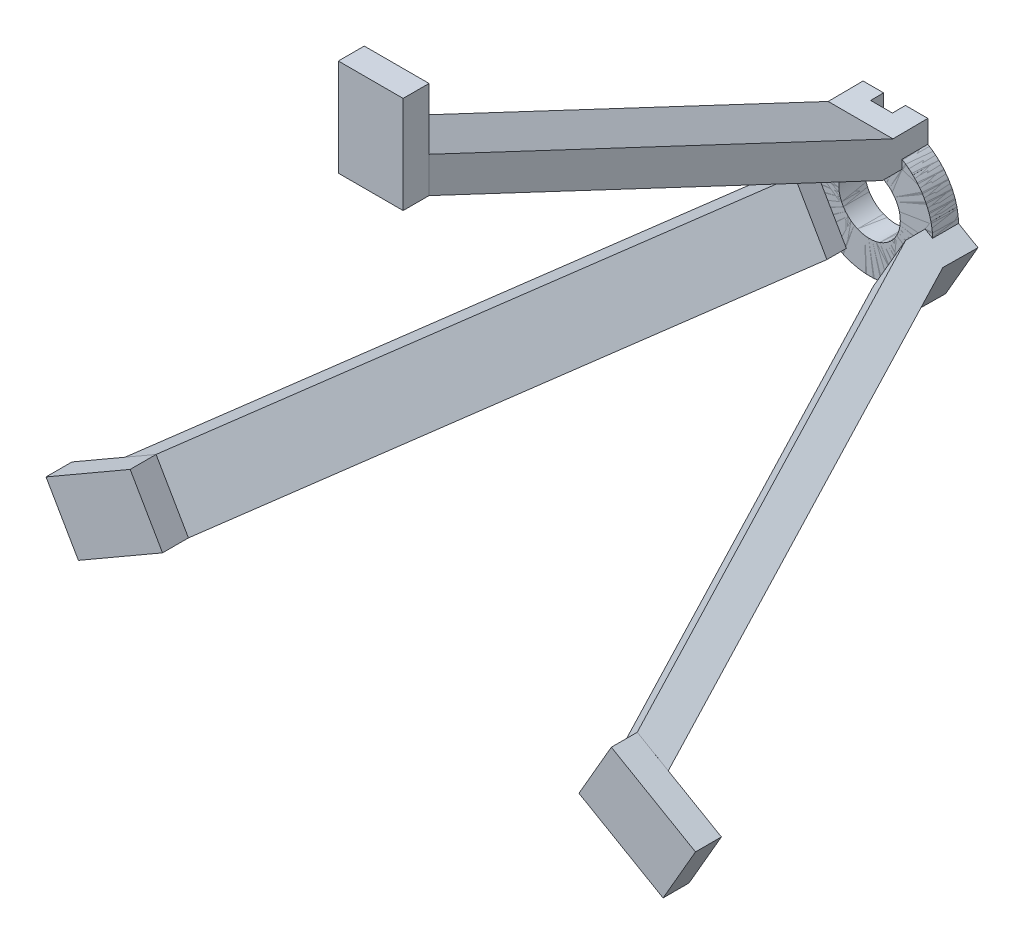
from build123d import *

# Parameters (mm, degrees)
SKETCH1_R                = 4.75
BOSS_EXTRUDE1_DEPTH      = 4
SKETCH2_W                = 10
SKETCH2_H                = 3.269716928
BOSS_EXTRUDE3_DEPTH      = 3
BOSS_EXTRUDE3_DEPTH_BACK = 2
SKETCH6_W                = 10
SKETCH6_H                = 15
BOSS_EXTRUDE4_DEPTH      = 4
BOSS_EXTRUDE5_DEPTH      = 10
CIRPATTERN1_COUNT        = 3
SKETCH8_W                = 3.367555941
SKETCH8_H                = 5.226269066
CUT_EXTRUDE1_DEPTH       = 2


with BuildPart() as part:
    # Sketch1 → Boss-Extrude1 (new body)
    with BuildSketch(Plane.XY):
        with BuildLine():
            Line((6.690811411, 7.091935043), (-6.690811411, 7.091935043))
            ThreePointArc((-6.690811411, 7.091935043), (-3.861805843, -8.95259491), (9.75, 0))
            ThreePointArc((9.75, 0), (8.95259491, 3.861805843), (6.690811411, 7.091935043))
        make_face()
        Circle(SKETCH1_R, mode=Mode.SUBTRACT)
    extrude(amount=BOSS_EXTRUDE1_DEPTH)

    # Sketch2 → Boss-Extrude3 (add, two sides)
    with BuildSketch(Plane.XY.offset(4)) as boss_extrude3_sk:
        with Locations((0, 8.652125422)):
            Rectangle(SKETCH2_W, SKETCH2_H)
    extrude(amount=BOSS_EXTRUDE3_DEPTH)
    extrude(boss_extrude3_sk.sketch, amount=-BOSS_EXTRUDE3_DEPTH_BACK)

    # Sketch7 → Boss-Extrude5 (add)
    with BuildSketch(Plane.ZY.offset(5)):
        Polygon((77, 40), (7, 7.017266958), (0, 7.017266958), (0, 11.828521069), (5.385727043, 11.783884206), (76.99663738, 45.525649042), align=None)
    extrude(amount=-BOSS_EXTRUDE5_DEPTH)


with BuildPart() as body_2:
    # Sketch6 → Boss-Extrude4 (new body)
    with BuildSketch(Plane.XY.offset(81)):
        with Locations((0, 47.5)):
            Rectangle(SKETCH6_W, SKETCH6_H)
    extrude(amount=-BOSS_EXTRUDE4_DEPTH)


with BuildPart() as cirpattern1_1:
    # CirPattern1: pattern copy
    add(body_2.part.rotate(Axis((0, 0, 0), (0, 0, 1)), 1 * 360 / CIRPATTERN1_COUNT))


with BuildPart() as cirpattern1_2:
    # CirPattern1: pattern copy
    add(body_2.part.rotate(Axis((0, 0, 0), (0, 0, 1)), 2 * 360 / CIRPATTERN1_COUNT))


with BuildPart() as cirpattern1_3:
    # CirPattern1: pattern copy
    add(part.part.rotate(Axis((0, 0, 0), (0, 0, 1)), 1 * 360 / CIRPATTERN1_COUNT))


with BuildPart() as cirpattern1_4:
    # CirPattern1: pattern copy
    add(part.part.rotate(Axis((0, 0, 0), (0, 0, 1)), 2 * 360 / CIRPATTERN1_COUNT))


with BuildPart() as cut_extrude1_tool:
    # Sketch8 → Cut-Extrude1 (new body)
    with BuildSketch(Plane(origin=(0, 0, 0), x_dir=(-1, 0, 0), z_dir=(0, 0, -1))):
        with Locations((0.145609817, 9.564429707)):
            Rectangle(SKETCH8_W, SKETCH8_H)
    extrude(amount=-CUT_EXTRUDE1_DEPTH)


with BuildPart() as part_1:
    add(part.part)

    # Cut-Extrude1: cut by cut_extrude1_tool
    add(cut_extrude1_tool.part, mode=Mode.SUBTRACT)


with BuildPart() as cirpattern1_3_1:
    add(cirpattern1_3.part)

    # Cut-Extrude1: cut by cut_extrude1_tool
    add(cut_extrude1_tool.part, mode=Mode.SUBTRACT)


with BuildPart() as cirpattern1_4_1:
    add(cirpattern1_4.part)

    # Cut-Extrude1: cut by cut_extrude1_tool
    add(cut_extrude1_tool.part, mode=Mode.SUBTRACT)


solid = Compound([body_2.part, cirpattern1_1.part, cirpattern1_2.part, part_1.part, cirpattern1_3_1.part, cirpattern1_4_1.part])
